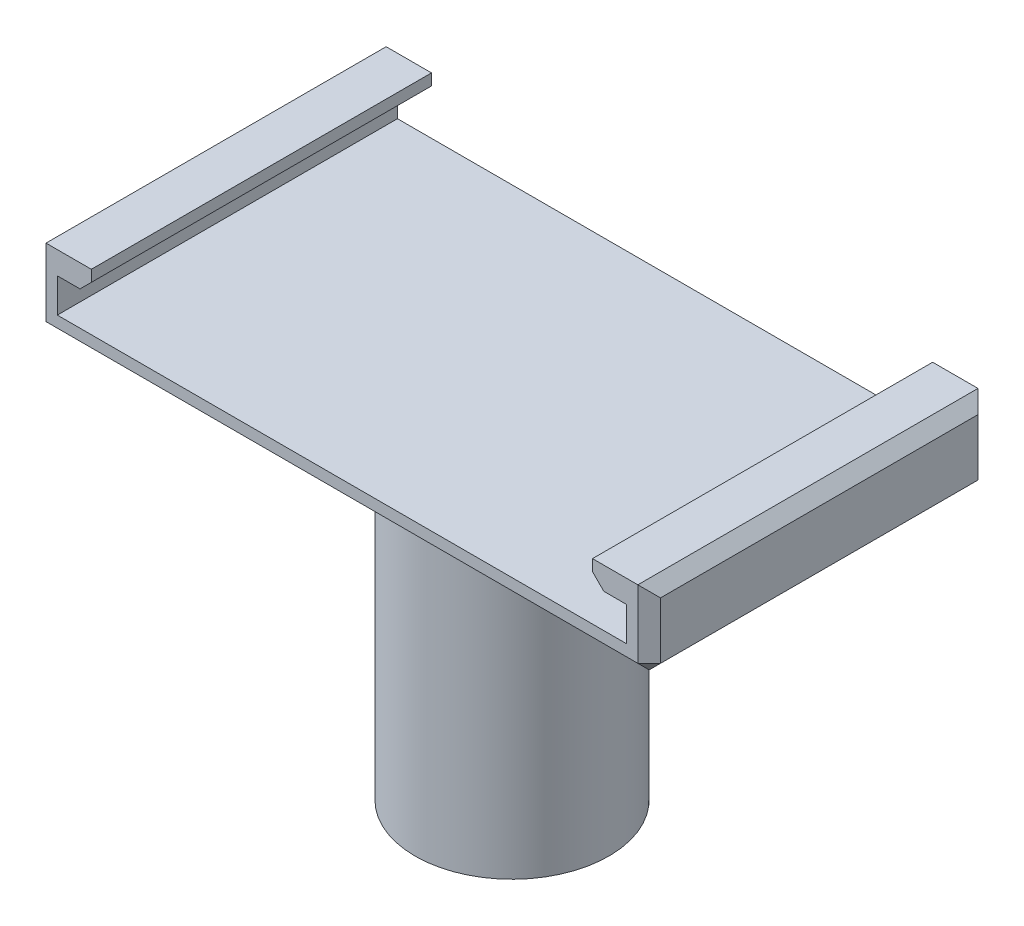
from build123d import *

# Parameters (mm, degrees)
SKETCH1_R           = 8.55
SKETCH1_R_2         = 7.55
BOSS_EXTRUDE1_DEPTH = 30
SKETCH2_R           = 8.55
BOSS_EXTRUDE2_DEPTH = 2
BOSS_EXTRUDE3_DEPTH = 2
SKETCH4_W           = 2
SKETCH4_H           = 30
BOSS_EXTRUDE4_DEPTH = 5
SKETCH6_W           = 30
SKETCH6_H           = 2
BOSS_EXTRUDE5_DEPTH = 3
SKETCH7_W           = 30
SKETCH7_H           = 2
BOSS_EXTRUDE6_DEPTH = 3
CHAMFER1_SIZE       = 3
CHAMFER2_SIZE       = 1
CHAMFER3_SIZE       = 1


with BuildPart() as part:
    # Sketch1 → Boss-Extrude1 (new body)
    with BuildSketch(Plane(origin=(0, 0, 0), x_dir=(1, 0, 0), z_dir=(0, 1, 0))):
        Circle(SKETCH1_R)
        Circle(SKETCH1_R_2, mode=Mode.SUBTRACT)
    extrude(amount=BOSS_EXTRUDE1_DEPTH)

    # Sketch2 → Boss-Extrude2 (add)
    with BuildSketch(Plane(origin=(0, 30, 0), x_dir=(1, 0, 0), z_dir=(0, 1, 0))):
        Circle(SKETCH2_R)
    extrude(amount=-BOSS_EXTRUDE2_DEPTH)

    # Sketch3 → Boss-Extrude3 (add)
    with BuildSketch(Plane(origin=(0, 30, 0), x_dir=(1, 0, 0), z_dir=(0, 1, 0))):
        Polygon((27.1, -15), (27.1, 15), (25, 15), (-25, 15), (-27.1, 15), (-27.1, -15), (-25, -15), (25, -15), align=None)
    extrude(amount=BOSS_EXTRUDE3_DEPTH)

    # Sketch4 → Boss-Extrude4 (add)
    with BuildSketch(Plane(origin=(0, 32, 0), x_dir=(1, 0, 0), z_dir=(0, 1, 0))):
        with Locations((-26.1, 0)):
            Rectangle(SKETCH4_W, SKETCH4_H)
        with Locations((26.1, 0)):
            Rectangle(SKETCH4_W, SKETCH4_H)
    extrude(amount=BOSS_EXTRUDE4_DEPTH)

    # Sketch6 → Boss-Extrude5 (add)
    with BuildSketch(Plane(origin=(-25.1, 0, 0), x_dir=(0, 0, -1), z_dir=(1, 0, 0))):
        with Locations((0, 36)):
            Rectangle(SKETCH6_W, SKETCH6_H)
    extrude(amount=BOSS_EXTRUDE5_DEPTH)

    # Sketch7 → Boss-Extrude6 (add)
    with BuildSketch(Plane.ZY.offset(-25.1)):
        with Locations((0, 36)):
            Rectangle(SKETCH7_W, SKETCH7_H)
    extrude(amount=BOSS_EXTRUDE6_DEPTH)

    # Chamfer1
    chamfer1_edges = [part.edges().sort_by_distance(p)[0] for p in [
        (-8.55, 30, 0),
    ]]
    chamfer(chamfer1_edges, length=CHAMFER1_SIZE)

    # Chamfer2
    chamfer2_edges = [part.edges().sort_by_distance(p)[0] for p in [
        (-22.1, 35, 0),
        (22.1, 35, 0),
    ]]
    chamfer(chamfer2_edges, length=CHAMFER2_SIZE)

    # Chamfer3
    chamfer3_edges = [part.edges().sort_by_distance(p)[0] for p in [
        (0, 30, -15),
        (27.1, 33.5, -15),
        (-27.1, 30, 0),
        (-27.1, 33.5, -15),
        (0, 30, 15),
        (-27.1, 33.5, 15),
        (27.1, 30, 0),
        (27.1, 33.5, 15),
        (-27.1, 37, 0),
        (27.1, 37, 0),
    ]]
    chamfer(chamfer3_edges, length=CHAMFER3_SIZE)


solid = part.part
